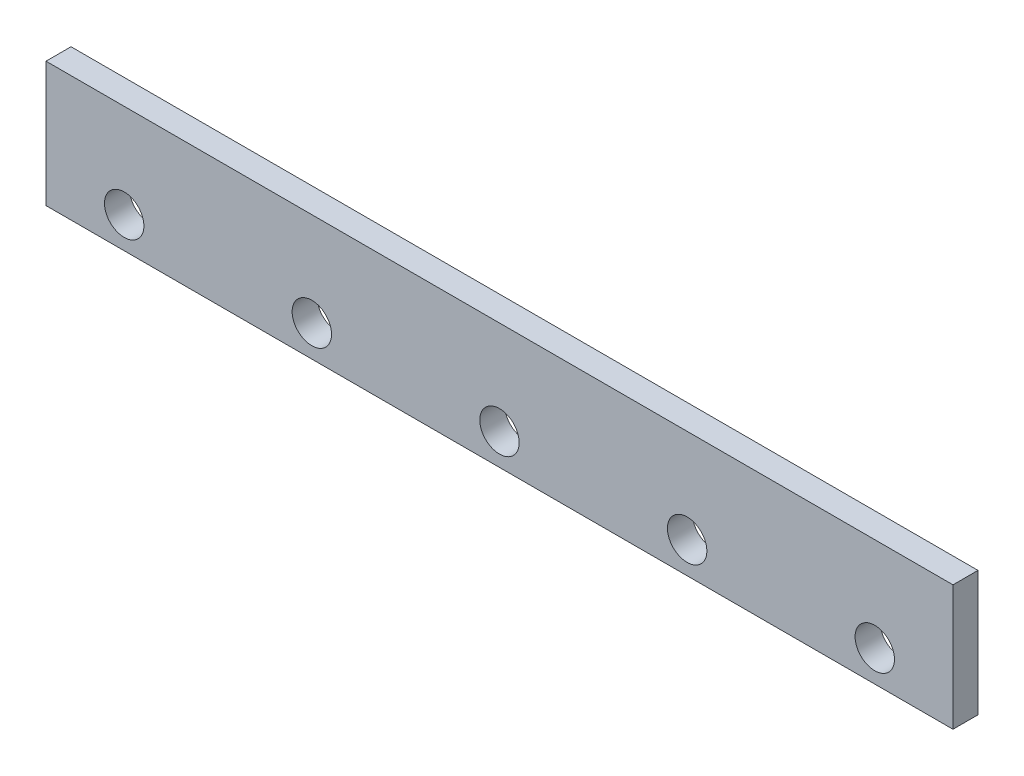
from build123d import *

# Parameters (mm, degrees)
SKETCH1_W           = 580
SKETCH1_H           = 80
SKETCH1_R           = 12.6
BOSS_EXTRUDE1_DEPTH = 16


with BuildPart() as part:
    # Sketch1 → Boss-Extrude1 (new body)
    with BuildSketch(Plane.XY):
        with Locations((290, 40)):
            Rectangle(SKETCH1_W, SKETCH1_H)
        with Locations((50, 20)):
            Circle(SKETCH1_R, mode=Mode.SUBTRACT)
        with Locations((170, 20)):
            Circle(SKETCH1_R, mode=Mode.SUBTRACT)
        with Locations((410, 20)):
            Circle(SKETCH1_R, mode=Mode.SUBTRACT)
        with Locations((290, 20)):
            Circle(SKETCH1_R, mode=Mode.SUBTRACT)
        with Locations((530, 20)):
            Circle(SKETCH1_R, mode=Mode.SUBTRACT)
    extrude(amount=BOSS_EXTRUDE1_DEPTH)


solid = part.part
